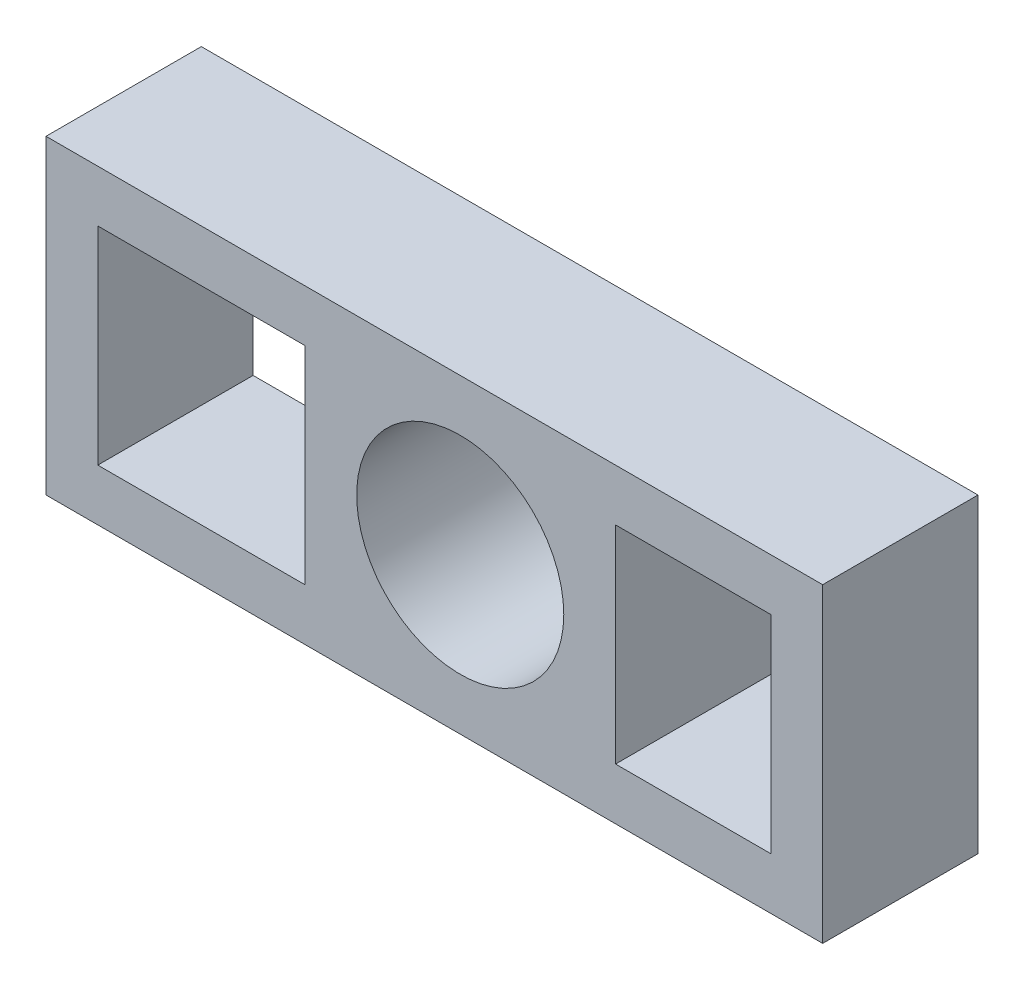
from build123d import *

# Parameters (mm, degrees)
SKETCH1_W           = 1905
SKETCH1_H           = 762
SKETCH1_R           = 254
SKETCH1_W_2         = 508
SKETCH1_H_2         = 508
SKETCH1_W_3         = 381
BOSS_EXTRUDE1_DEPTH = 381


with BuildPart() as part:
    # Sketch1 → Boss-Extrude1 (new body)
    with BuildSketch(Plane.XY):
        with Locations((952.5, 381)):
            Rectangle(SKETCH1_W, SKETCH1_H)
        with Locations((1016, 381)):
            Circle(SKETCH1_R, mode=Mode.SUBTRACT)
        with Locations((381, 381)):
            Rectangle(SKETCH1_W_2, SKETCH1_H_2, mode=Mode.SUBTRACT)
        with Locations((1587.5, 381)):
            Rectangle(SKETCH1_W_3, SKETCH1_H_2, mode=Mode.SUBTRACT)
    extrude(amount=BOSS_EXTRUDE1_DEPTH)


solid = part.part
